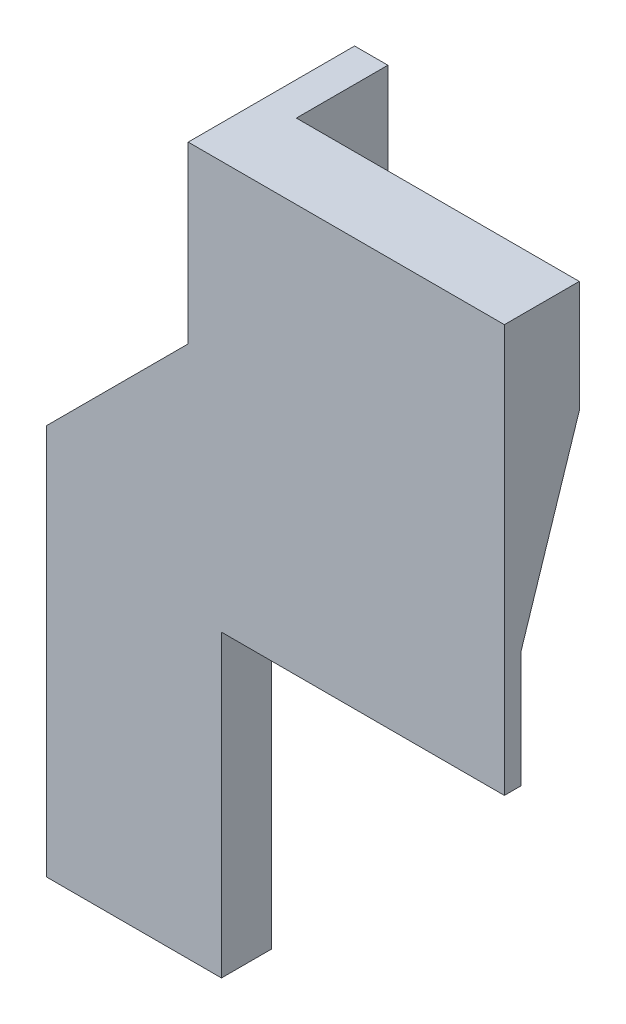
from build123d import *

# Parameters (mm, degrees)
BOSS_EXTRUDE1_DEPTH = 2
BOSS_EXTRUDE2_DEPTH = 30
SKETCH3_W           = 15
SKETCH3_H           = 50
BOSS_EXTRUDE3_DEPTH = 4
BOSS_EXTRUDE4_DEPTH = 6
BOSS_EXTRUDE5_DEPTH = 14
CUT_EXTRUDE1_DEPTH  = 26
BOSS_EXTRUDE6_DEPTH = 4


with BuildPart() as part:
    # Sketch1 → Boss-Extrude1 (new body)
    with BuildSketch(Plane.XY):
        Polygon((-15, 0), (-15, 36), (15, 36), (15, 50), (15, 111), (-15, 111), (-15, 50), (-30, 50), (-30, 0), align=None)
    extrude(amount=BOSS_EXTRUDE1_DEPTH)

    # Sketch2 → Boss-Extrude2 (add)
    with BuildSketch(Plane(origin=(15, 0, 0), x_dir=(0, 0, -1), z_dir=(1, 0, 0))):
        Polygon((0, 50), (7, 71.54378476), (7, 111), (0, 111), align=None)
    extrude(amount=-BOSS_EXTRUDE2_DEPTH)

    # Sketch3 → Boss-Extrude3 (add)
    with BuildSketch(Plane(origin=(0, 0, 0), x_dir=(-1, 0, 0), z_dir=(0, 0, -1))):
        with Locations((22.5, 25)):
            Rectangle(SKETCH3_W, SKETCH3_H)
    extrude(amount=BOSS_EXTRUDE3_DEPTH)

    # Sketch4 → Boss-Extrude4 (add)
    with BuildSketch(Plane(origin=(0, 0, -4), x_dir=(-1, 0, 0), z_dir=(0, 0, -1))):
        Polygon((15, 111), (15, 50), (30, 50), (30, 0), (36, 0), (36, 47), (19, 64), (19, 111), align=None)
    extrude(amount=-BOSS_EXTRUDE4_DEPTH)

    # Sketch5 → Boss-Extrude5 (add)
    with BuildSketch(Plane(origin=(0, 0, -4), x_dir=(-1, 0, 0), z_dir=(0, 0, -1))):
        Polygon((32, 0), (32, 45.343145751), (15, 62.343145751), (15, 111), (19, 111), (19, 64), (36, 47), (36, 0), align=None)
    extrude(amount=BOSS_EXTRUDE5_DEPTH)

    # Sketch6 → Cut-Extrude1 (cut)
    with BuildSketch(Plane(origin=(0, 111, 0), x_dir=(1, 0, 0), z_dir=(0, 1, 0))):
        Polygon((15, 7), (-15, 7), (-15, 18), (-19, 18), (-19, -2), (15, -2), align=None)
    extrude(amount=-CUT_EXTRUDE1_DEPTH, mode=Mode.SUBTRACT)

    # Sketch7 → Boss-Extrude6 (add)
    with BuildSketch(Plane(origin=(15, 0, 0), x_dir=(0, 0, -1), z_dir=(1, 0, 0))):
        Polygon((7, 85), (-2, 85), (-2, 36), (0, 36), (0, 50), (7, 71.54378476), align=None)
    extrude(amount=BOSS_EXTRUDE6_DEPTH)


solid = part.part
